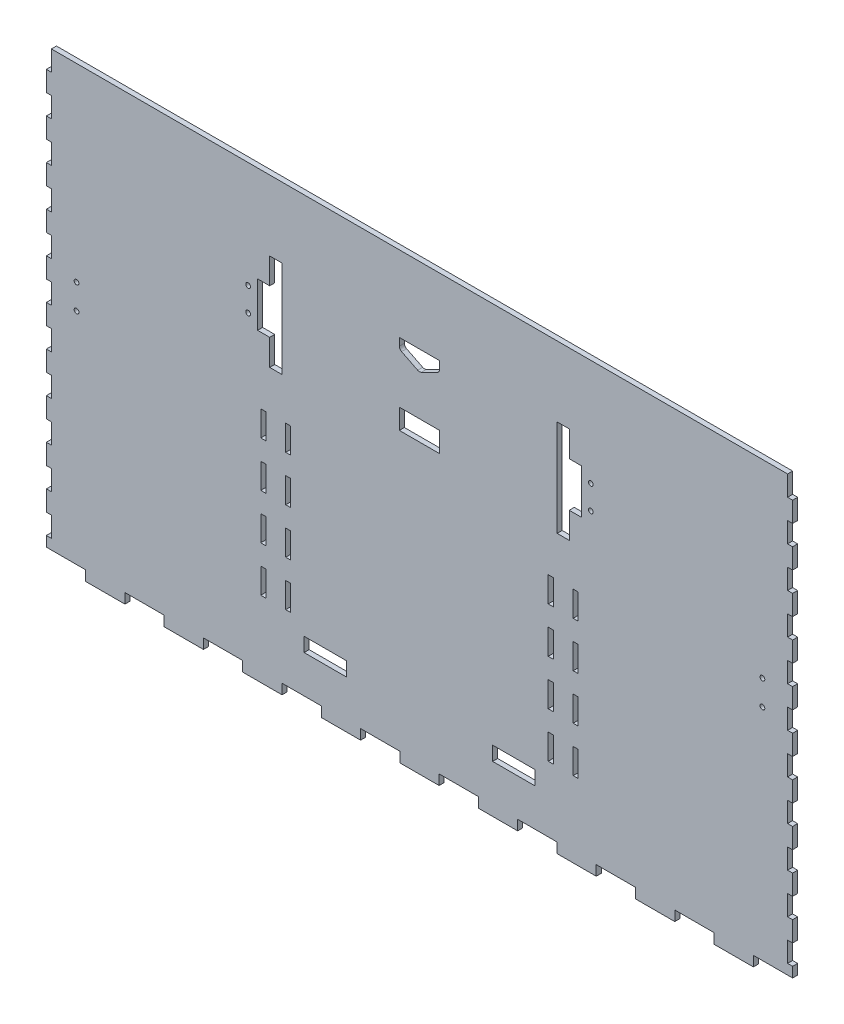
from build123d import *

# Parameters (mm, degrees)
SKETCH1_W                 = 470.789
SKETCH1_H                 = 139.7
BOSS_EXTRUDE1_DEPTH       = 6.35
SKETCH2_W                 = 470.789
SKETCH2_H                 = 139.7
SKETCH2_W_2               = 464.439
SKETCH2_H_2               = 133.35
BOSS_EXTRUDE2_DEPTH       = 299.212
SKETCH3_W                 = 10.033
SKETCH3_H                 = 260.604
SKETCH3_W_2               = 5.588
SKETCH3_H_2               = 16.933333333
SKETCH3_H_3               = 16.933333334
DOOR_SLOT_DEPTH           = 12.7
DOOR_GUIDE_HOLES_REACH    = 411.167
SKETCH4_W                 = 3.175
SKETCH4_H                 = 15.9512
LEVERHOLE_CUT_REACH       = 412.237
LEVER_HOLES_W             = 26.67
LEVER_HOLES_H             = 8.89
LEVER_HOLES_2_R           = 1.499997
LBRACKET_THRU_HOLES_DEPTH = 411.237487895
SKETCH8_R                 = 3.175
TETHER_HOLE_DEPTH         = 566.587695115
HEIGHTREDUCTION_REACH     = 412.237
SKETCH15_W                = 136.525
SKETCH15_H                = 280.162
FRONT_BACK_CUT_DEPTH      = 553.278961454
FRONT_BACK_W              = 24.778368421
FRONT_BACK_H              = 6.35
FRONT_BACK_W_2            = 3.175
FRONT_BACK_H_2            = 12.734636363
FRONT_BACK_H_3            = 12.734636364
JOINT_CUT_DEPTH           = 392.685341664
SWITCH_HOLE_R             = 1.499997
SWITCH_CUT_DEPTH          = 366.939062549
CUT_EXTRUDE1_DEPTH        = 366.939062549
CUT_EXTRUDE1_DEPTH_BACK   = 366.939062549
SKETCH17_W                = 25.4
SKETCH17_H                = 12.7
FILLET1_R                 = 2.54


with BuildPart() as part:
    # Sketch1 → Boss-Extrude1 (new body)
    with BuildSketch(Plane(origin=(0, 0, 0), x_dir=(1, 0, 0), z_dir=(0, 1, 0))):
        Rectangle(SKETCH1_W, SKETCH1_H)
    extrude(amount=BOSS_EXTRUDE1_DEPTH)

    # Sketch2 → Boss-Extrude2 (add)
    with BuildSketch(Plane(origin=(0, 6.35, 0), x_dir=(1, 0, 0), z_dir=(0, 1, 0))):
        Rectangle(SKETCH2_W, SKETCH2_H)
        Rectangle(SKETCH2_W_2, SKETCH2_H_2, mode=Mode.SUBTRACT)
    extrude(amount=BOSS_EXTRUDE2_DEPTH)

    # Sketch3 → Door Slot (cut)
    with BuildSketch(Plane.XY.offset(69.85)):
        with Locations((-90.678, 136.652)):
            Rectangle(SKETCH3_W, SKETCH3_H)
        with Locations((90.678, 136.652)):
            Rectangle(SKETCH3_W, SKETCH3_H)
        with Locations((75.7555, 80.433333334)):
            Rectangle(SKETCH3_W_2, SKETCH3_H_2)
        with Locations((75.7555, 50.8)):
            Rectangle(SKETCH3_W_2, SKETCH3_H_3)
        with Locations((75.7555, 21.166666667)):
            Rectangle(SKETCH3_W_2, SKETCH3_H_2)
        with Locations((-75.7555, 80.433333334)):
            Rectangle(SKETCH3_W_2, SKETCH3_H_2)
        with Locations((-75.7555, 50.8)):
            Rectangle(SKETCH3_W_2, SKETCH3_H_3)
        with Locations((-75.7555, 21.166666667)):
            Rectangle(SKETCH3_W_2, SKETCH3_H_2)
    extrude(amount=-DOOR_SLOT_DEPTH, mode=Mode.SUBTRACT)

    # Sketch4 → Door Guide Holes (cut, up to next)
    with BuildSketch(Plane.XY.offset(-66.675), mode=Mode.PRIVATE) as door_guide_holes_sk1:
        with Locations((82.804, 141.6304)):
            Rectangle(SKETCH4_W, SKETCH4_H)
    door_guide_holes_tool1 = extrude(door_guide_holes_sk1.sketch, amount=-DOOR_GUIDE_HOLES_REACH, mode=Mode.PRIVATE) & part.part
    # Sketch4 → Door Guide Holes (cut, up to next)
    with BuildSketch(Plane.XY.offset(-66.675), mode=Mode.PRIVATE) as door_guide_holes_sk2:
        with Locations((82.804, 112.9792)):
            Rectangle(SKETCH4_W, SKETCH4_H)
    door_guide_holes_tool2 = extrude(door_guide_holes_sk2.sketch, amount=-DOOR_GUIDE_HOLES_REACH, mode=Mode.PRIVATE) & part.part
    # Sketch4 → Door Guide Holes (cut, up to next)
    with BuildSketch(Plane.XY.offset(-66.675), mode=Mode.PRIVATE) as door_guide_holes_sk3:
        with Locations((82.804, 84.328)):
            Rectangle(SKETCH4_W, SKETCH4_H)
    door_guide_holes_tool3 = extrude(door_guide_holes_sk3.sketch, amount=-DOOR_GUIDE_HOLES_REACH, mode=Mode.PRIVATE) & part.part
    # Sketch4 → Door Guide Holes (cut, up to next)
    with BuildSketch(Plane.XY.offset(-66.675), mode=Mode.PRIVATE) as door_guide_holes_sk4:
        with Locations((82.804, 55.6768)):
            Rectangle(SKETCH4_W, SKETCH4_H)
    door_guide_holes_tool4 = extrude(door_guide_holes_sk4.sketch, amount=-DOOR_GUIDE_HOLES_REACH, mode=Mode.PRIVATE) & part.part
    # Sketch4 → Door Guide Holes (cut, up to next)
    with BuildSketch(Plane.XY.offset(-66.675), mode=Mode.PRIVATE) as door_guide_holes_sk5:
        with Locations((98.552, 141.6304)):
            Rectangle(SKETCH4_W, SKETCH4_H)
    door_guide_holes_tool5 = extrude(door_guide_holes_sk5.sketch, amount=-DOOR_GUIDE_HOLES_REACH, mode=Mode.PRIVATE) & part.part
    # Sketch4 → Door Guide Holes (cut, up to next)
    with BuildSketch(Plane.XY.offset(-66.675), mode=Mode.PRIVATE) as door_guide_holes_sk6:
        with Locations((98.552, 112.9792)):
            Rectangle(SKETCH4_W, SKETCH4_H)
    door_guide_holes_tool6 = extrude(door_guide_holes_sk6.sketch, amount=-DOOR_GUIDE_HOLES_REACH, mode=Mode.PRIVATE) & part.part
    # Sketch4 → Door Guide Holes (cut, up to next)
    with BuildSketch(Plane.XY.offset(-66.675), mode=Mode.PRIVATE) as door_guide_holes_sk7:
        with Locations((98.552, 84.328)):
            Rectangle(SKETCH4_W, SKETCH4_H)
    door_guide_holes_tool7 = extrude(door_guide_holes_sk7.sketch, amount=-DOOR_GUIDE_HOLES_REACH, mode=Mode.PRIVATE) & part.part
    # Sketch4 → Door Guide Holes (cut, up to next)
    with BuildSketch(Plane.XY.offset(-66.675), mode=Mode.PRIVATE) as door_guide_holes_sk8:
        with Locations((98.552, 55.6768)):
            Rectangle(SKETCH4_W, SKETCH4_H)
    door_guide_holes_tool8 = extrude(door_guide_holes_sk8.sketch, amount=-DOOR_GUIDE_HOLES_REACH, mode=Mode.PRIVATE) & part.part
    # Sketch4 → Door Guide Holes (cut, up to next)
    with BuildSketch(Plane.XY.offset(-66.675), mode=Mode.PRIVATE) as door_guide_holes_sk9:
        with Locations((-98.552, 141.6304)):
            Rectangle(SKETCH4_W, SKETCH4_H)
    door_guide_holes_tool9 = extrude(door_guide_holes_sk9.sketch, amount=-DOOR_GUIDE_HOLES_REACH, mode=Mode.PRIVATE) & part.part
    # Sketch4 → Door Guide Holes (cut, up to next)
    with BuildSketch(Plane.XY.offset(-66.675), mode=Mode.PRIVATE) as door_guide_holes_sk10:
        with Locations((-98.552, 112.9792)):
            Rectangle(SKETCH4_W, SKETCH4_H)
    door_guide_holes_tool10 = extrude(door_guide_holes_sk10.sketch, amount=-DOOR_GUIDE_HOLES_REACH, mode=Mode.PRIVATE) & part.part
    # Sketch4 → Door Guide Holes (cut, up to next)
    with BuildSketch(Plane.XY.offset(-66.675), mode=Mode.PRIVATE) as door_guide_holes_sk11:
        with Locations((-98.552, 84.328)):
            Rectangle(SKETCH4_W, SKETCH4_H)
    door_guide_holes_tool11 = extrude(door_guide_holes_sk11.sketch, amount=-DOOR_GUIDE_HOLES_REACH, mode=Mode.PRIVATE) & part.part
    # Sketch4 → Door Guide Holes (cut, up to next)
    with BuildSketch(Plane.XY.offset(-66.675), mode=Mode.PRIVATE) as door_guide_holes_sk12:
        with Locations((-98.552, 55.6768)):
            Rectangle(SKETCH4_W, SKETCH4_H)
    door_guide_holes_tool12 = extrude(door_guide_holes_sk12.sketch, amount=-DOOR_GUIDE_HOLES_REACH, mode=Mode.PRIVATE) & part.part
    # Sketch4 → Door Guide Holes (cut, up to next)
    with BuildSketch(Plane.XY.offset(-66.675), mode=Mode.PRIVATE) as door_guide_holes_sk13:
        with Locations((-82.804, 141.6304)):
            Rectangle(SKETCH4_W, SKETCH4_H)
    door_guide_holes_tool13 = extrude(door_guide_holes_sk13.sketch, amount=-DOOR_GUIDE_HOLES_REACH, mode=Mode.PRIVATE) & part.part
    # Sketch4 → Door Guide Holes (cut, up to next)
    with BuildSketch(Plane.XY.offset(-66.675), mode=Mode.PRIVATE) as door_guide_holes_sk14:
        with Locations((-82.804, 112.9792)):
            Rectangle(SKETCH4_W, SKETCH4_H)
    door_guide_holes_tool14 = extrude(door_guide_holes_sk14.sketch, amount=-DOOR_GUIDE_HOLES_REACH, mode=Mode.PRIVATE) & part.part
    # Sketch4 → Door Guide Holes (cut, up to next)
    with BuildSketch(Plane.XY.offset(-66.675), mode=Mode.PRIVATE) as door_guide_holes_sk15:
        with Locations((-82.804, 84.328)):
            Rectangle(SKETCH4_W, SKETCH4_H)
    door_guide_holes_tool15 = extrude(door_guide_holes_sk15.sketch, amount=-DOOR_GUIDE_HOLES_REACH, mode=Mode.PRIVATE) & part.part
    # Sketch4 → Door Guide Holes (cut, up to next)
    with BuildSketch(Plane.XY.offset(-66.675), mode=Mode.PRIVATE) as door_guide_holes_sk16:
        with Locations((-82.804, 55.6768)):
            Rectangle(SKETCH4_W, SKETCH4_H)
    door_guide_holes_tool16 = extrude(door_guide_holes_sk16.sketch, amount=-DOOR_GUIDE_HOLES_REACH, mode=Mode.PRIVATE) & part.part
    add(door_guide_holes_tool1.solids().sort_by_distance((82.804, 141.6304, -66.675))[0], mode=Mode.SUBTRACT)
    add(door_guide_holes_tool2.solids().sort_by_distance((82.804, 112.9792, -66.675))[0], mode=Mode.SUBTRACT)
    add(door_guide_holes_tool3.solids().sort_by_distance((82.804, 84.328, -66.675))[0], mode=Mode.SUBTRACT)
    add(door_guide_holes_tool4.solids().sort_by_distance((82.804, 55.6768, -66.675))[0], mode=Mode.SUBTRACT)
    add(door_guide_holes_tool5.solids().sort_by_distance((98.552, 141.6304, -66.675))[0], mode=Mode.SUBTRACT)
    add(door_guide_holes_tool6.solids().sort_by_distance((98.552, 112.9792, -66.675))[0], mode=Mode.SUBTRACT)
    add(door_guide_holes_tool7.solids().sort_by_distance((98.552, 84.328, -66.675))[0], mode=Mode.SUBTRACT)
    add(door_guide_holes_tool8.solids().sort_by_distance((98.552, 55.6768, -66.675))[0], mode=Mode.SUBTRACT)
    add(door_guide_holes_tool9.solids().sort_by_distance((-98.552, 141.6304, -66.675))[0], mode=Mode.SUBTRACT)
    add(door_guide_holes_tool10.solids().sort_by_distance((-98.552, 112.9792, -66.675))[0], mode=Mode.SUBTRACT)
    add(door_guide_holes_tool11.solids().sort_by_distance((-98.552, 84.328, -66.675))[0], mode=Mode.SUBTRACT)
    add(door_guide_holes_tool12.solids().sort_by_distance((-98.552, 55.6768, -66.675))[0], mode=Mode.SUBTRACT)
    add(door_guide_holes_tool13.solids().sort_by_distance((-82.804, 141.6304, -66.675))[0], mode=Mode.SUBTRACT)
    add(door_guide_holes_tool14.solids().sort_by_distance((-82.804, 112.9792, -66.675))[0], mode=Mode.SUBTRACT)
    add(door_guide_holes_tool15.solids().sort_by_distance((-82.804, 84.328, -66.675))[0], mode=Mode.SUBTRACT)
    add(door_guide_holes_tool16.solids().sort_by_distance((-82.804, 55.6768, -66.675))[0], mode=Mode.SUBTRACT)

    # Lever Holes → LeverHole Cut (cut, up to next)
    with BuildSketch(Plane.XY.offset(-69.85), mode=Mode.PRIVATE) as leverhole_cut_sk1:
        with Locations((-59.46650007, 34.5099894)):
            Rectangle(LEVER_HOLES_W, LEVER_HOLES_H)
    leverhole_cut_tool1 = extrude(leverhole_cut_sk1.sketch, amount=LEVERHOLE_CUT_REACH, mode=Mode.PRIVATE) & part.part
    # Lever Holes → LeverHole Cut (cut, up to next)
    with BuildSketch(Plane.XY.offset(-69.85), mode=Mode.PRIVATE) as leverhole_cut_sk2:
        with Locations((59.46650007, 34.5099894)):
            Rectangle(LEVER_HOLES_W, LEVER_HOLES_H)
    leverhole_cut_tool2 = extrude(leverhole_cut_sk2.sketch, amount=LEVERHOLE_CUT_REACH, mode=Mode.PRIVATE) & part.part
    add(leverhole_cut_tool1.solids().sort_by_distance((-59.4665, 34.509989, -69.85))[0], mode=Mode.SUBTRACT)
    add(leverhole_cut_tool2.solids().sort_by_distance((59.4665, 34.509989, -69.85))[0], mode=Mode.SUBTRACT)

    # Lever Holes_2 → Lbracket Thru Holes (cut, through all)
    with BuildSketch(Plane.XY.offset(-69.85)):
        with Locations((216.3445, 160.655)):
            Circle(LEVER_HOLES_2_R)
        with Locations((216.3445, 144.907)):
            Circle(LEVER_HOLES_2_R)
        with Locations((-216.3445, 160.655)):
            Circle(LEVER_HOLES_2_R)
        with Locations((-216.3445, 144.907)):
            Circle(LEVER_HOLES_2_R)
    extrude(amount=LBRACKET_THRU_HOLES_DEPTH, mode=Mode.SUBTRACT)

    # Sketch8 → Tether Hole (cut, through all)
    with BuildSketch(Plane.ZY.offset(235.3945)):
        with Locations((0, 11.43)):
            Circle(SKETCH8_R)
    extrude(amount=-TETHER_HOLE_DEPTH, mode=Mode.SUBTRACT)

    # Sketch16 → HeightReduction (cut, up to next)
    with BuildSketch(Plane.XY.offset(69.85), mode=Mode.PRIVATE) as heightreduction_sk1:
        Polygon((53.721, 280.162), (63.246, 280.162), (118.11, 280.162), (127.635, 280.162), (235.3945, 280.162), (235.3945, 305.562), (-235.3945, 305.562), (-235.3945, 280.162), (-127.635, 280.162), (-118.11, 280.162), (-63.246, 280.162), (-53.721, 280.162), align=None)
    heightreduction_tool1 = extrude(heightreduction_sk1.sketch, amount=-HEIGHTREDUCTION_REACH, mode=Mode.PRIVATE) & part.part
    add(heightreduction_tool1.solids().sort_by_distance((0, 292.862, 69.85))[0], mode=Mode.SUBTRACT)

    # Sketch15 → Front_Back Cut (cut, through all)
    with BuildSketch(Plane.ZY.offset(235.3945)):
        with Locations((1.5875, 140.081)):
            Rectangle(SKETCH15_W, SKETCH15_H)
    extrude(amount=-FRONT_BACK_CUT_DEPTH, mode=Mode.SUBTRACT)

    # Front_Back → Joint Cut (cut, through all)
    with BuildSketch(Plane.XY.offset(69.85)):
        with Locations((-223.00531579, 3.175)):
            Rectangle(FRONT_BACK_W, FRONT_BACK_H)
        with Locations((-233.807, 19.101954545)):
            Rectangle(FRONT_BACK_W_2, FRONT_BACK_H_2)
        with Locations((-173.448578948, 3.175)):
            Rectangle(FRONT_BACK_W, FRONT_BACK_H)
        with Locations((-233.807, 44.571227273)):
            Rectangle(FRONT_BACK_W_2, FRONT_BACK_H_3)
        with Locations((-123.891842106, 3.175)):
            Rectangle(FRONT_BACK_W, FRONT_BACK_H)
        with Locations((-233.807, 70.0405)):
            Rectangle(FRONT_BACK_W_2, FRONT_BACK_H_3)
        with Locations((-74.335105263, 3.175)):
            Rectangle(FRONT_BACK_W, FRONT_BACK_H)
        with Locations((-233.807, 95.509772727)):
            Rectangle(FRONT_BACK_W_2, FRONT_BACK_H_3)
        with Locations((-24.778368422, 3.175)):
            Rectangle(FRONT_BACK_W, FRONT_BACK_H)
        with Locations((-233.807, 120.979045455)):
            Rectangle(FRONT_BACK_W_2, FRONT_BACK_H_2)
        with Locations((24.778368422, 3.175)):
            Rectangle(FRONT_BACK_W, FRONT_BACK_H)
        with Locations((-233.807, 146.448318182)):
            Rectangle(FRONT_BACK_W_2, FRONT_BACK_H_3)
        with Locations((74.335105263, 3.175)):
            Rectangle(FRONT_BACK_W, FRONT_BACK_H)
        with Locations((-233.807, 171.917590909)):
            Rectangle(FRONT_BACK_W_2, FRONT_BACK_H_3)
        with Locations((123.891842106, 3.175)):
            Rectangle(FRONT_BACK_W, FRONT_BACK_H)
        with Locations((-233.807, 197.386863637)):
            Rectangle(FRONT_BACK_W_2, FRONT_BACK_H_2)
        with Locations((173.448578948, 3.175)):
            Rectangle(FRONT_BACK_W, FRONT_BACK_H)
        with Locations((-233.807, 222.856136364)):
            Rectangle(FRONT_BACK_W_2, FRONT_BACK_H_2)
        with Locations((223.00531579, 3.175)):
            Rectangle(FRONT_BACK_W, FRONT_BACK_H)
        with Locations((-233.807, 248.325409091)):
            Rectangle(FRONT_BACK_W_2, FRONT_BACK_H_3)
        with Locations((233.807, 19.101954545)):
            Rectangle(FRONT_BACK_W_2, FRONT_BACK_H_2)
        with Locations((-233.807, 273.794681818)):
            Rectangle(FRONT_BACK_W_2, FRONT_BACK_H_3)
        with Locations((233.807, 44.571227273)):
            Rectangle(FRONT_BACK_W_2, FRONT_BACK_H_3)
        with Locations((233.807, 70.0405)):
            Rectangle(FRONT_BACK_W_2, FRONT_BACK_H_3)
        with Locations((233.807, 95.509772727)):
            Rectangle(FRONT_BACK_W_2, FRONT_BACK_H_3)
        with Locations((233.807, 120.979045455)):
            Rectangle(FRONT_BACK_W_2, FRONT_BACK_H_2)
        with Locations((233.807, 146.448318182)):
            Rectangle(FRONT_BACK_W_2, FRONT_BACK_H_3)
        with Locations((233.807, 171.917590909)):
            Rectangle(FRONT_BACK_W_2, FRONT_BACK_H_3)
        with Locations((233.807, 197.386863637)):
            Rectangle(FRONT_BACK_W_2, FRONT_BACK_H_2)
        with Locations((233.807, 222.856136364)):
            Rectangle(FRONT_BACK_W_2, FRONT_BACK_H_2)
        with Locations((233.807, 248.325409091)):
            Rectangle(FRONT_BACK_W_2, FRONT_BACK_H_3)
        with Locations((233.807, 273.794681818)):
            Rectangle(FRONT_BACK_W_2, FRONT_BACK_H_3)
    extrude(amount=-JOINT_CUT_DEPTH, mode=Mode.SUBTRACT)

    # Switch Hole → Switch Cut (cut, through all)
    with BuildSketch(Plane.XY.offset(-66.675)):
        Polygon((-86.868, 235.9060052), (-94.488, 235.9060052), (-94.488, 219.583), (-102.108, 219.583), (-102.108, 191.4560052), (-94.488, 191.4560052), (-94.488, 175.006), (-86.868, 175.006), align=None)
        Polygon((94.488, 191.4560052), (102.108, 191.4560052), (102.108, 219.583), (94.488, 219.583), (94.488, 235.9060052), (86.868, 235.9060052), (86.868, 175.006), (94.488, 175.006), align=None)
        with Locations((-108.107988, 212.9560003)):
            Circle(SWITCH_HOLE_R)
        with Locations((-108.107988, 197.9560049)):
            Circle(SWITCH_HOLE_R)
        with Locations((108.107988, 197.9560049)):
            Circle(SWITCH_HOLE_R)
        with Locations((108.107988, 212.9560003)):
            Circle(SWITCH_HOLE_R)
    extrude(amount=-SWITCH_CUT_DEPTH, mode=Mode.SUBTRACT)

    # Sketch17 → Cut-Extrude1 (cut, two sides: drawn at the far end of the back side and taken through both)
    with BuildSketch(Plane.XY.offset(-66.675).offset(-CUT_EXTRUDE1_DEPTH_BACK)):
        Polygon((12.7, 232.283), (-12.7, 232.283), (-12.7, 225.933), (0, 219.583), (12.7, 225.933), align=None)
        with Locations((0, 187.833)):
            Rectangle(SKETCH17_W, SKETCH17_H)
    extrude(amount=CUT_EXTRUDE1_DEPTH + CUT_EXTRUDE1_DEPTH_BACK, mode=Mode.SUBTRACT)

    # Fillet1
    fillet1_edges = [part.edges().sort_by_distance(p)[0] for p in [
        (0, 219.583, -68.2625),
        (-12.7, 225.933, -68.2625),
        (12.7, 225.933, -68.2625),
    ]]
    fillet(fillet1_edges, radius=FILLET1_R)


solid = part.part
